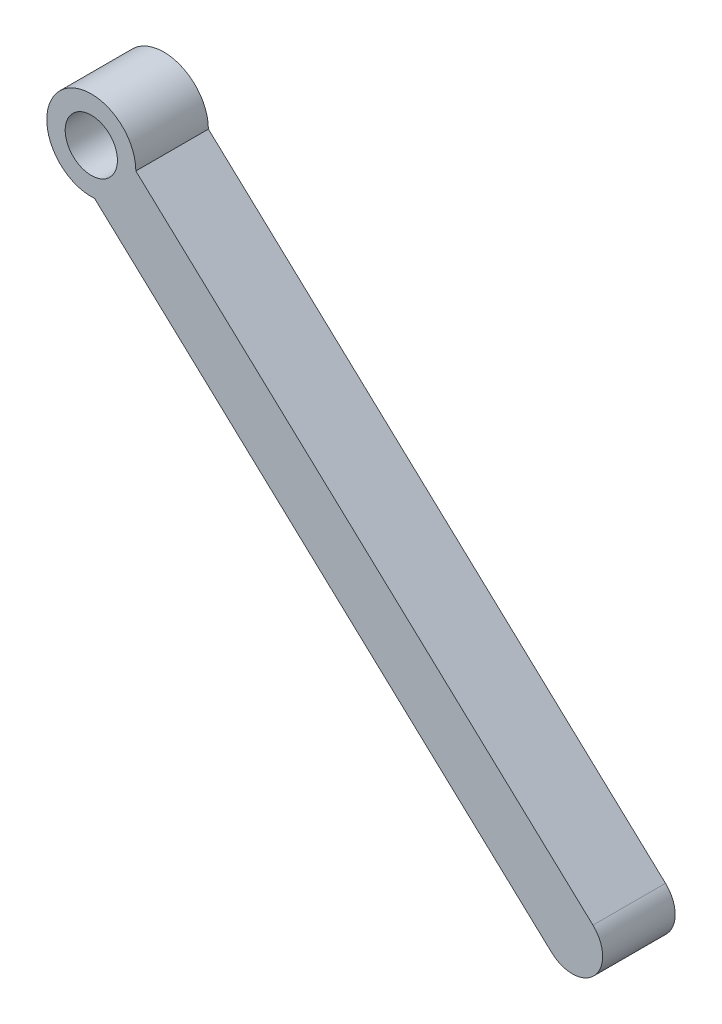
from build123d import *

# Parameters (mm, degrees)
ESQUISSE2_R        = 1.8
BOSS_EXTRU_2_DEPTH = 5


with BuildPart() as part:
    # Esquisse2 → Boss.-Extru.2 (new body)
    with BuildSketch(Plane.XY):
        with BuildLine():
            Line((17.591007248, -13.591370514), (-13.915745379, 15.671652893))
            ThreePointArc((-13.915745379, 15.671652893), (-14.736105314, 13.582929731), (-16.758645601, 12.610774569))
            Line((-16.758645601, 12.610774569), (14.748107026, -16.652248837))
            ThreePointArc((14.748107026, -16.652248837), (17.699996299, -16.543259786), (17.591007248, -13.591370514))
        make_face()
        with BuildLine():
            Line((-16.758645601, 12.610774569), (-20.0542154, 15.671652893))
            ThreePointArc((-20.0542154, 15.671652893), (-19.073703551, 13.422777818), (-16.758645601, 12.610774569))
        make_face()
        with BuildLine():
            ThreePointArc((-16.758645601, 12.610774569), (-14.736105314, 13.582929731), (-13.915745379, 15.671652893))
            ThreePointArc((-13.915745379, 15.671652893), (-16.984980389, 18.740887903), (-20.0542154, 15.671652893))
            Line((-20.0542154, 15.671652893), (-16.758645601, 12.610774569))
        make_face()
        with Locations((-16.984980389, 15.671652893)):
            Circle(ESQUISSE2_R, mode=Mode.SUBTRACT)
    extrude(amount=BOSS_EXTRU_2_DEPTH)


solid = part.part
